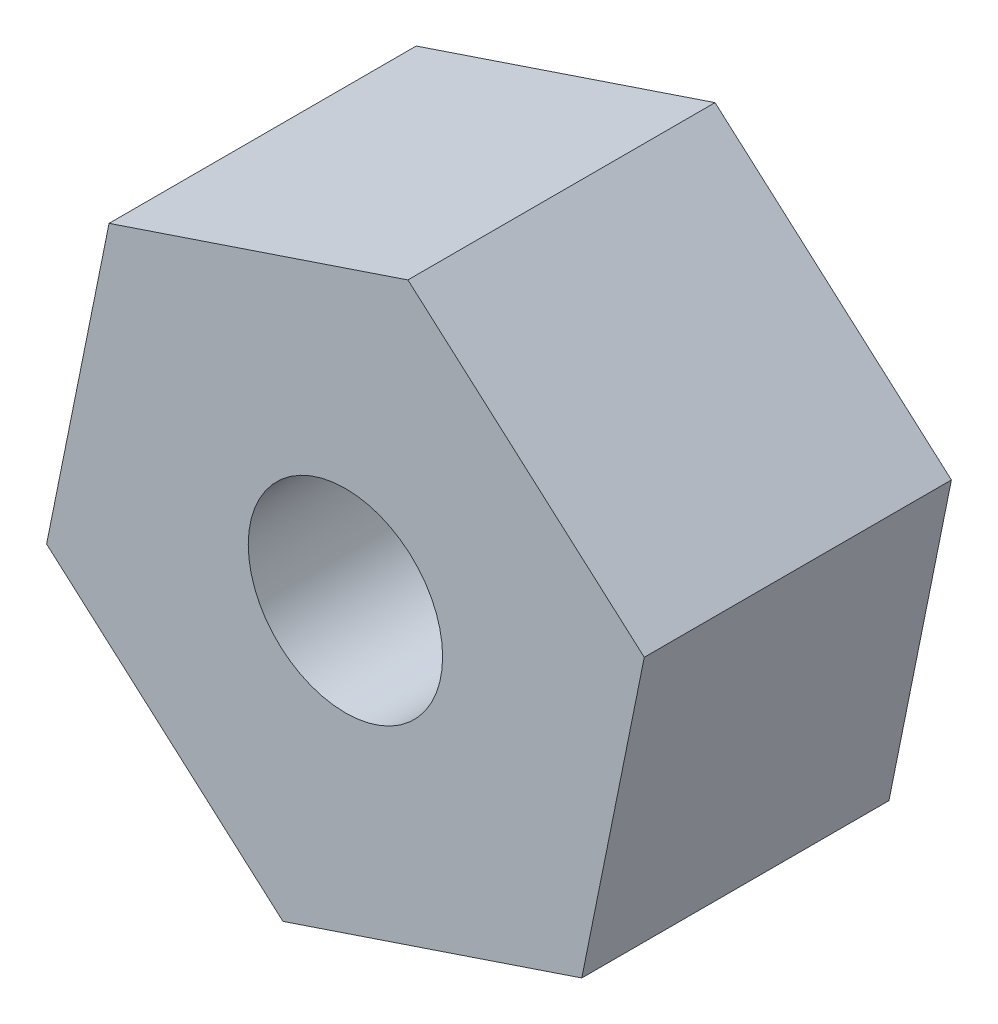
from build123d import *

# Parameters (mm, degrees)
SKETCH1_R      = 1.1303
EXTRUDE1_DEPTH = 3.571875


with BuildPart() as part:
    # Sketch1 → Extrude1 (new body)
    with BuildSketch(Plane.XY):
        Polygon((3.475292101, 1.167552202), (0.726516183, 3.593467346), (-2.748775918, 2.425915144), (-3.475292101, -1.167552202), (-0.726516183, -3.593467346), (2.748775918, -2.425915144), align=None)
        Circle(SKETCH1_R, mode=Mode.SUBTRACT)
    extrude(amount=EXTRUDE1_DEPTH)


solid = part.part
